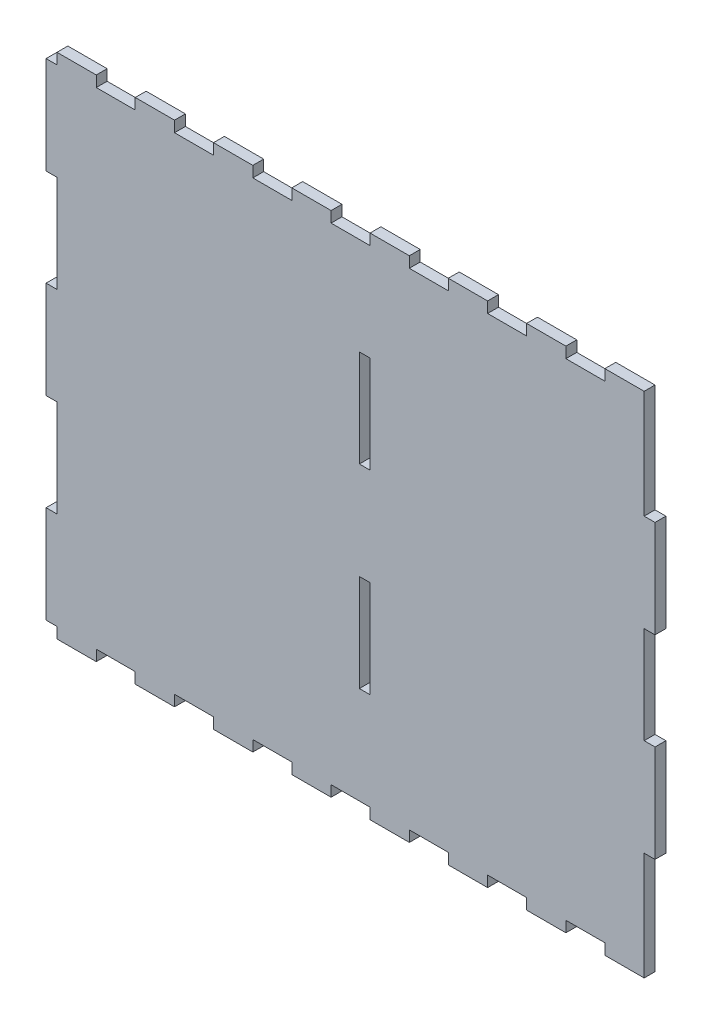
from build123d import *

# Parameters (mm, degrees)
SKETCH1_W           = 5.4
SKETCH1_H           = 48.265
BOSS_EXTRUDE1_DEPTH = 5.4
SKETCH2_W           = 5.31872
SKETCH2_H           = 48.18372
BOSS_EXTRUDE2_DEPTH = 5.4


with BuildPart() as part:
    # Sketch1 → Boss-Extrude1 (new body)
    with BuildSketch(Plane.XY):
        Polygon((-181.028382108, -13.967555325), (-181.028382108, -8.567555325), (-200.453382108, -8.567555325), (-200.453382108, -13.967555325), (-219.878382108, -13.967555325), (-219.878382108, -8.567555325), (-239.303382108, -8.567555325), (-239.303382108, -13.967555325), (-244.703382108, -13.967555325), (-244.703382108, -62.232555325), (-239.303382108, -62.232555325), (-239.303382108, -110.497555325), (-244.703382108, -110.497555325), (-244.703382108, -158.762555325), (-239.303382108, -158.762555325), (-239.303382108, -207.027555325), (-244.703382109, -207.027555325), (-244.703382109, -255.292555325), (-239.303382108, -255.292555325), (-239.303382108, -260.692555325), (-219.878382108, -260.692555325), (-219.878382108, -255.292555325), (-200.453382108, -255.292555325), (-200.453382108, -260.692555325), (-181.028382108, -260.692555325), (-181.028382108, -255.292555325), (-161.603382108, -255.292555325), (-161.603382108, -260.692555325), (-142.178382108, -260.692555325), (-142.178382108, -255.292555325), (-122.753382108, -255.292555325), (-122.753382108, -260.692555325), (-103.328382108, -260.692555325), (-103.328382108, -255.292555325), (-83.903382108, -255.292555325), (-83.903382108, -260.692555325), (-64.478382108, -260.692555325), (-64.478382108, -255.292555325), (-45.053382108, -255.292555325), (-45.053382108, -260.692555325), (-25.628382108, -260.692555325), (-25.628382108, -255.292555325), (-6.203382108, -255.292555325), (-6.203382108, -260.692555325), (13.221617892, -260.692555325), (13.221617892, -255.292555325), (32.646617892, -255.292555325), (32.646617892, -260.692555325), (52.071617892, -260.692555325), (52.071617892, -207.027555325), (57.471617892, -207.027555325), (57.471617892, -158.762555325), (52.071617892, -158.762555325), (52.071617892, -110.497555325), (57.471617892, -110.497555325), (57.471617892, -62.232555325), (52.071617892, -62.232555325), (52.071617892, -8.567555325), (32.646617892, -8.567555325), (32.646617892, -13.967555325), (13.221617892, -13.967555325), (13.221617892, -8.567555325), (-6.203382108, -8.567555325), (-6.203382108, -13.967555325), (-25.628382108, -13.967555325), (-25.628382108, -8.567555325), (-45.053382108, -8.567555325), (-45.053382108, -13.967555325), (-64.478382108, -13.967555325), (-64.478382108, -8.567555325), (-83.903382108, -8.567555325), (-83.903382108, -13.967555325), (-103.328382108, -13.967555325), (-103.328382108, -8.567555325), (-122.753382108, -8.567555325), (-122.753382108, -13.967555325), (-142.178382108, -13.967555325), (-142.178382108, -8.567555325), (-161.603382108, -8.567555325), (-161.603382108, -13.967555325), align=None)
        with Locations((-86.578382108, -182.895055325)):
            Rectangle(SKETCH1_W, SKETCH1_H, mode=Mode.SUBTRACT)
        with Locations((-86.578382108, -86.365055325)):
            Rectangle(SKETCH1_W, SKETCH1_H, mode=Mode.SUBTRACT)
    extrude(amount=BOSS_EXTRUDE1_DEPTH)

    # Sketch2 → Boss-Extrude2 (add)
    with BuildSketch(Plane.XY.offset(5.4)):
        Polygon((-239.344022108, -8.526915325), (-239.344022108, -13.926915325), (-244.744022108, -13.926915325), (-244.744022108, -62.273195325), (-239.344022108, -62.273195325), (-239.344022108, -110.456915325), (-244.744022108, -110.456915325), (-244.744022108, -158.803195325), (-239.344022108, -158.803195325), (-239.344022108, -206.986915325), (-244.744022109, -206.986915325), (-244.744022109, -255.333195325), (-239.344022108, -255.333195325), (-239.344022108, -260.733195325), (-219.837742108, -260.733195325), (-219.837742108, -255.333195325), (-200.494022108, -255.333195325), (-200.494022108, -260.733195325), (-180.987742108, -260.733195325), (-180.987742108, -255.333195325), (-161.644022108, -255.333195325), (-161.644022108, -260.733195325), (-142.137742108, -260.733195325), (-142.137742108, -255.333195325), (-122.794022108, -255.333195325), (-122.794022108, -260.733195325), (-103.287742108, -260.733195325), (-103.287742108, -255.333195325), (-83.944022108, -255.333195325), (-83.944022108, -260.733195325), (-64.437742108, -260.733195325), (-64.437742108, -255.333195325), (-45.094022108, -255.333195325), (-45.094022108, -260.733195325), (-25.587742108, -260.733195325), (-25.587742108, -255.333195325), (-6.244022108, -255.333195325), (-6.244022108, -260.733195325), (13.262257892, -260.733195325), (13.262257892, -255.333195325), (32.605977892, -255.333195325), (32.605977892, -260.733195325), (52.112257892, -260.733195325), (52.112257892, -207.068195325), (57.512257892, -207.068195325), (57.512257892, -158.721915325), (52.112257892, -158.721915325), (52.112257892, -110.538195325), (57.512257892, -110.538195325), (57.512257892, -62.191915325), (52.112257892, -62.191915325), (52.112257892, -8.526915325), (32.605977892, -8.526915325), (32.605977892, -13.926915325), (13.262257892, -13.926915325), (13.262257892, -8.526915325), (-6.244022108, -8.526915325), (-6.244022108, -13.926915325), (-25.587742108, -13.926915325), (-25.587742108, -8.526915325), (-45.094022108, -8.526915325), (-45.094022108, -13.926915325), (-64.437742108, -13.926915325), (-64.437742108, -8.526915325), (-83.944022108, -8.526915325), (-83.944022108, -13.926915325), (-103.287742108, -13.926915325), (-103.287742108, -8.526915325), (-122.794022108, -8.526915325), (-122.794022108, -13.926915325), (-142.137742108, -13.926915325), (-142.137742108, -8.526915325), (-161.644022108, -8.526915325), (-161.644022108, -13.926915325), (-180.987742108, -13.926915325), (-180.987742108, -8.526915325), (-200.494022108, -8.526915325), (-200.494022108, -13.926915325), (-219.837742108, -13.926915325), (-219.837742108, -8.526915325), align=None)
        with Locations((-86.578382108, -86.365055325)):
            Rectangle(SKETCH2_W, SKETCH2_H, mode=Mode.SUBTRACT)
        with Locations((-86.578382108, -182.895055325)):
            Rectangle(SKETCH2_W, SKETCH2_H, mode=Mode.SUBTRACT)
    extrude(amount=-BOSS_EXTRUDE2_DEPTH)


solid = part.part
